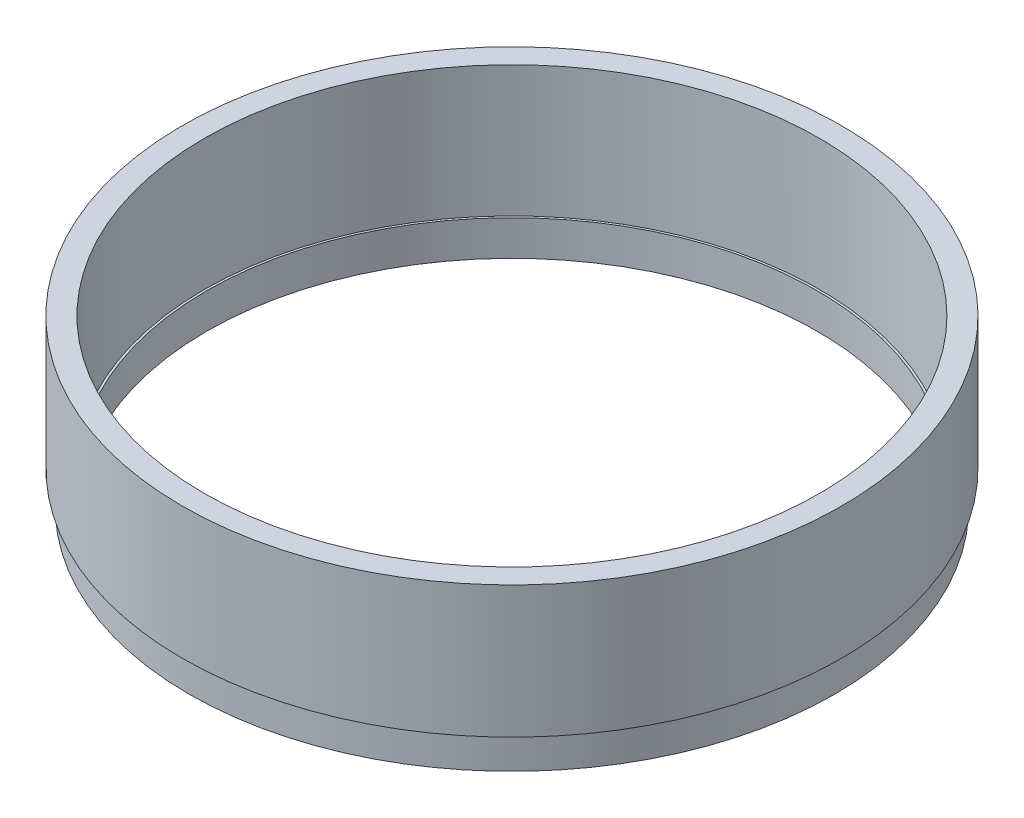
from build123d import *

# Parameters (mm, degrees)
CROQUIS1_R              = 37.5
CROQUIS1_R_2            = 35
SALIENTE_EXTRUIR1_DEPTH = 15
CROQUIS3_W              = 2
CROQUIS3_H              = 4


with BuildPart() as part:
    # Croquis1 → Saliente-Extruir1 (new body)
    with BuildSketch(Plane(origin=(0, 0, 0), x_dir=(1, 0, 0), z_dir=(0, 1, 0))):
        with Locations((13.541348433, 6.626768313)):
            Circle(CROQUIS1_R)
        with Locations((13.541348433, 6.626768313)):
            Circle(CROQUIS1_R_2, mode=Mode.SUBTRACT)
    extrude(amount=SALIENTE_EXTRUIR1_DEPTH)

    # Barrer1: sweep along a path in Croquis4
    with BuildLine(Plane(origin=(0, -1, 0), x_dir=(-1, 0, 0), z_dir=(0, -1, 0))) as barrer1_path:
        CenterArc((-13.541348433, 6.626768313), 36.25, 0, 360)
    # Croquis3 → Barrer1 (sweep)
    with BuildSketch(Plane.XY.offset(-6.626768313)):
        with Locations((-22.208651567, -1.9)):
            Rectangle(CROQUIS3_W, CROQUIS3_H)
    sweep(path=barrer1_path.line)


solid = part.part
